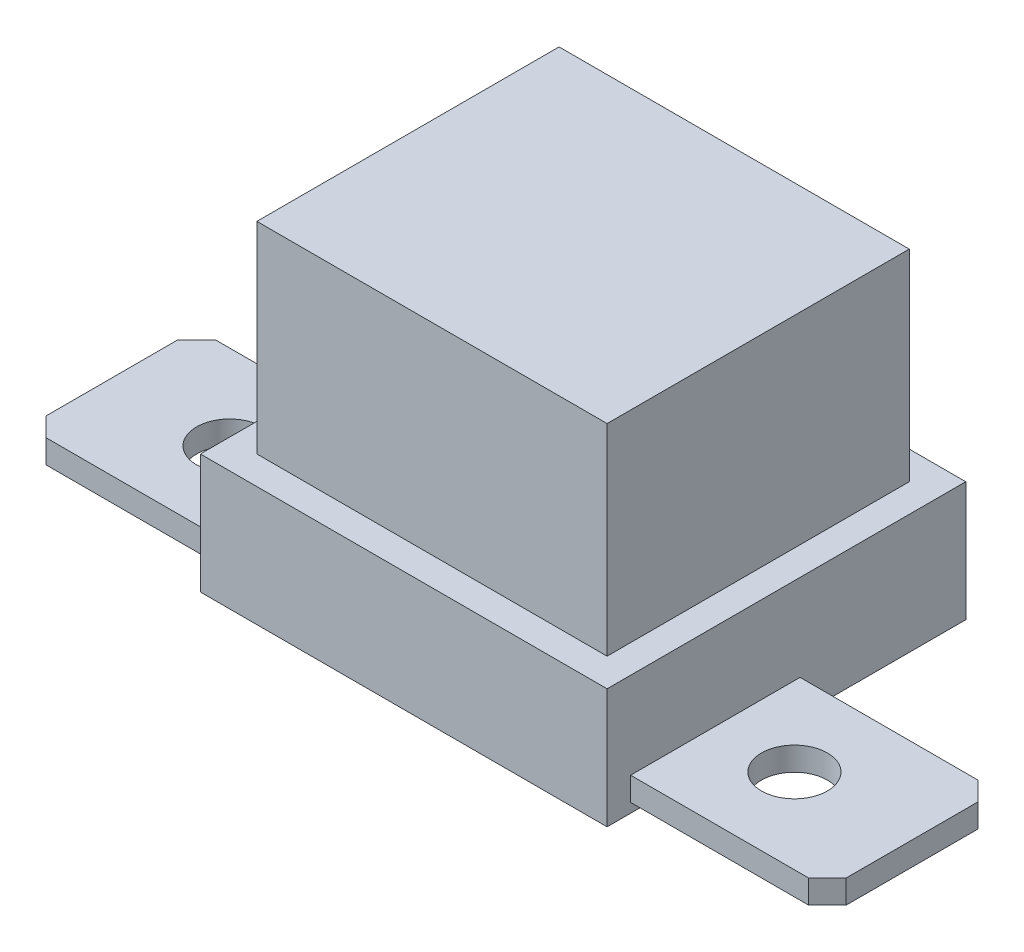
from build123d import *

# Parameters (mm, degrees)
SKETCH1_W           = 37.2
SKETCH1_H           = 32.1
BOSS_EXTRUDE1_DEPTH = 34.1
SKETCH1_4_W         = 43.2
SKETCH1_4_H         = 38.1
SKETCH1_4_W_2       = 37.2
SKETCH1_4_H_2       = 32.1
BOSS_EXTRUDE2_DEPTH = 12.7
BOSS_EXTRUDE3_START = 1
SKETCH2_R           = 3.5
BOSS_EXTRUDE3_DEPTH = 2.5


with BuildPart() as part:
    # Sketch1 → Boss-Extrude1 (new body)
    with BuildSketch(Plane(origin=(0, 0, 0), x_dir=(1, 0, 0), z_dir=(0, 1, 0))):
        Rectangle(SKETCH1_W, SKETCH1_H)
    extrude(amount=BOSS_EXTRUDE1_DEPTH)

    # Sketch1_4 → Boss-Extrude2 (add)
    with BuildSketch(Plane(origin=(0, 0, 0), x_dir=(1, 0, 0), z_dir=(0, 1, 0))):
        Rectangle(SKETCH1_4_W, SKETCH1_4_H)
        Rectangle(SKETCH1_4_W_2, SKETCH1_4_H_2, mode=Mode.SUBTRACT)
    extrude(amount=BOSS_EXTRUDE2_DEPTH)

    # Sketch2 → Boss-Extrude3 (add)
    # profile 1 of 2: a face of its own
    with BuildSketch(Plane(origin=(0, 0, 0), x_dir=(1, 0, 0), z_dir=(0, 1, 0)).offset(BOSS_EXTRUDE3_START)):
        Polygon((-21.6, 1.45), (-40.5, 1.45), (-42.5, -0.55), (-42.5, -14.55), (-40.5, -16.55), (-21.6, -16.55), align=None)
        with Locations((-30, -7.55)):
            Circle(SKETCH2_R, mode=Mode.SUBTRACT)
    # profile 2 of 2: a face of its own
    with BuildSketch(Plane(origin=(0, 0, 0), x_dir=(1, 0, 0), z_dir=(0, 1, 0)).offset(BOSS_EXTRUDE3_START)):
        Polygon((21.6, -16.55), (40.5, -16.55), (42.5, -14.55), (42.5, -0.55), (40.5, 1.45), (21.6, 1.45), align=None)
        with Locations((30, -7.55)):
            Circle(SKETCH2_R, mode=Mode.SUBTRACT)
    extrude(amount=BOSS_EXTRUDE3_DEPTH)


solid = part.part
